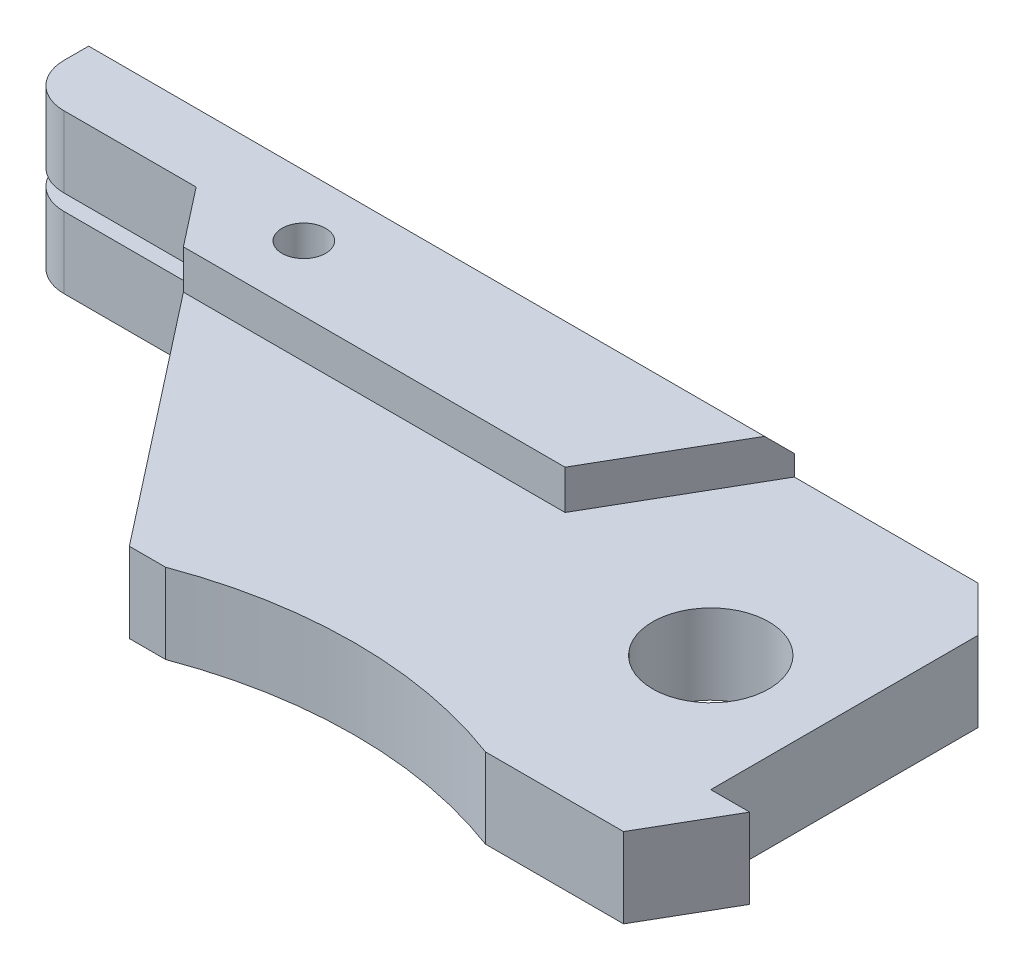
from build123d import *

# Parameters (mm, degrees)
SKETCH1_R           = 4
SKETCH1_R_2         = 1.5
BOSS_EXTRUDE1_DEPTH = 2.75
SKETCH2_R           = 1.5
BOSS_EXTRUDE2_DEPTH = 2.7
CUT_EXTRUDE1_DEPTH  = 0.55
FILLET1_R           = 3
CHAMFER1_SIZE       = 1.3
CUT_EXTRUDE3_DEPTH  = 2.7


with BuildPart() as part:
    # Sketch1 → Boss-Extrude1 (new body)
    with BuildSketch(Plane(origin=(0, 0, 0), x_dir=(1, 0, 0), z_dir=(0, 1, 0))):
        with BuildLine():
            Line((4.884776311, 13.5), (-55, 13.5))
            Line((-55, 13.5), (-55, 7.5))
            Line((-55, 7.5), (-42.906998157, 7.5))
            Line((-42.906998157, 7.5), (-26.5, -13.5))
            Line((-26.5, -13.5), (-24, -13.5))
            ThreePointArc((-24, -13.5), (-13, -11.5), (-2, -13.5))
            Line((-2, -13.5), (7.5, -13.5))
            Line((7.5, -13.5), (10.675426481, -8))
            Line((10.675426481, -8), (8, -8))
            Line((8, -8), (8, 10.384776311))
            Line((8, 10.384776311), (4.884776311, 13.5))
        make_face()
        Circle(SKETCH1_R, mode=Mode.SUBTRACT)
        with Locations((-36, 8)):
            Circle(SKETCH1_R_2, mode=Mode.SUBTRACT)
    extrude(amount=BOSS_EXTRUDE1_DEPTH)

    # Sketch2 → Boss-Extrude2 (add)
    with BuildSketch(Plane(origin=(0, 2.75, 0), x_dir=(1, 0, 0), z_dir=(0, 1, 0))):
        Polygon((-39.781855651, 3.5), (-13.523502692, 3.5), (-7.75, 13.5), (-55, 13.5), (-55, 7.5), (-42.906998157, 7.5), align=None)
        with Locations((-36, 8)):
            Circle(SKETCH2_R, mode=Mode.SUBTRACT)
    extrude(amount=BOSS_EXTRUDE2_DEPTH)

    # Sketch3 → Cut-Extrude1 (cut)
    with BuildSketch(Plane.XZ):
        Polygon((-23, -10.5), (-55, -10.5), (-55, 9.5), (-7.37428747, 9.5), align=None)
    extrude(amount=-CUT_EXTRUDE1_DEPTH, mode=Mode.SUBTRACT)

    # Fillet1
    fillet1_edges = [part.edges().sort_by_distance(p)[0] for p in [
        (-55, 3, -7.5),
    ]]
    fillet(fillet1_edges, radius=FILLET1_R)

    # Chamfer1
    chamfer1_edges = [part.edges().sort_by_distance(p)[0] for p in [
        (-31.375, 5.45, -13.5),
    ]]
    chamfer(chamfer1_edges, length=CHAMFER1_SIZE)

    # Mirror1: part across plane


with BuildPart() as part_1:
    add(part.part)
    add(part.part.mirror(Plane.ZX))

    # Sketch6 → Cut-Extrude3 (cut)
    with BuildSketch(Plane.XZ.offset(5.45)):
        Polygon((-32.218144349, -3.5), (-28.311716217, -8.5), (-10.636751346, -8.5), (-13.523502692, -3.5), align=None)
    extrude(amount=-CUT_EXTRUDE3_DEPTH, mode=Mode.SUBTRACT)

    # Sketch7 → Cut-Revolve1 (revolve, cut)
    with BuildSketch(Plane(origin=(0, 0, 0), x_dir=(0.999390827, 0, 0.034899497), z_dir=(-0.034899497, 0, 0.999390827))):
        with BuildLine():
            Line((-10, -2.75), (-10, -1.75))
            ThreePointArc((-10, -1.75), (-11.118033989, -2.013932023), (-12, -2.75))
            Line((-12, -2.75), (-10, -2.75))
        make_face()
    revolve(axis=Axis((-9.99390827, -10.952082058, -0.348994967), (0, 1, 0)), mode=Mode.SUBTRACT)


solid = part_1.part
